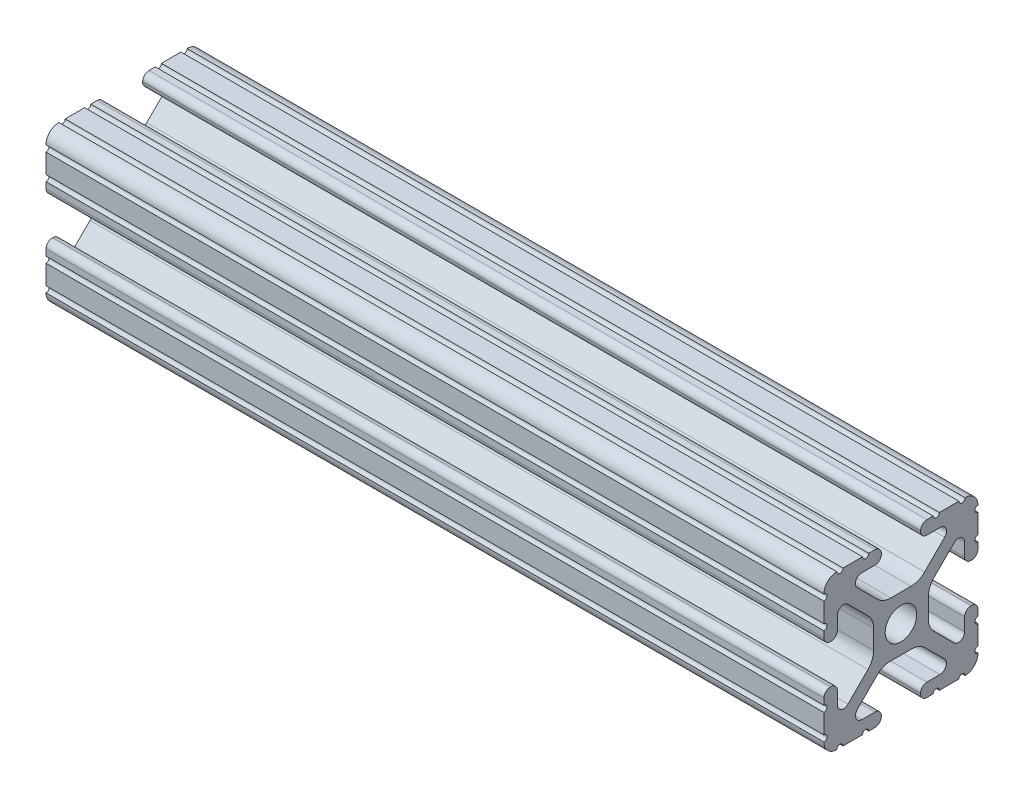
from build123d import *

# Parameters (mm, degrees)
SKETCH11_R                = 2.6035
F_10_1010_PROFILE_1_DEPTH = 128.27


with BuildPart() as part:
    # Sketch11 → 10 1010 PROFILE(1) (new body)
    with BuildSketch(Plane.ZY):
        with BuildLine():
            Line((-1.709253557, -4.4958), (1.709253557, -4.4958))
            ThreePointArc((1.709253557, -4.4958), (2.922935876, -4.736928798), (3.95226937, -5.423689619))
            Line((3.95226937, -5.423689619), (7.179652728, -8.645192207))
            ThreePointArc((7.179652728, -8.645192207), (7.414733441, -9.822812921), (6.41641086, -10.4902))
            Line((6.41641086, -10.4902), (4.28752, -10.4902))
            ThreePointArc((4.28752, -10.4902), (3.545750844, -10.797450844), (3.2385, -11.53922))
            Line((3.2385, -11.53922), (3.2385, -11.65098))
            ThreePointArc((3.2385, -11.65098), (3.545750844, -12.392749156), (4.28752, -12.7))
            Line((4.28752, -12.7), (5.3171344, -12.7))
            ThreePointArc((5.3171344, -12.7), (5.8251344, -12.192), (6.3331344, -12.7))
            Line((6.3331344, -12.7), (9.5504, -12.7))
            ThreePointArc((9.5504, -12.7), (10.058323491, -12.192000006), (10.566399977, -12.699846982))
            ThreePointArc((10.566399977, -12.699846982), (12.082522516, -12.082522516), (12.699846982, -10.566399977))
            ThreePointArc((12.699846982, -10.566399977), (12.192000006, -10.058323491), (12.7, -9.5504))
            Line((12.7, -9.5504), (12.7, -6.3330836))
            ThreePointArc((12.7, -6.3330836), (12.192, -5.8250836), (12.7, -5.3170836))
            Line((12.7, -5.3170836), (12.7, -4.287470133))
            ThreePointArc((12.7, -4.287470133), (12.392749156, -3.545700977), (11.65098, -3.238450133))
            Line((11.65098, -3.238450133), (11.53922, -3.238450133))
            ThreePointArc((11.53922, -3.238450133), (10.797450844, -3.545700977), (10.4902, -4.287470133))
            Line((10.4902, -4.287470133), (10.4902, -6.402089023))
            ThreePointArc((10.4902, -6.402089023), (9.856394933, -7.351113629), (8.736962546, -7.129240479))
            Line((8.736962546, -7.129240479), (5.440484187, -3.838768792))
            ThreePointArc((5.440484187, -3.838768792), (4.75073678, -2.808015636), (4.5085, -1.591658411))
            Line((4.5085, -1.591658411), (4.5085, 1.591658411))
            ThreePointArc((4.5085, 1.591658411), (4.75073678, 2.808015636), (5.440484187, 3.838768792))
            Line((5.440484187, 3.838768792), (8.736962546, 7.129240479))
            ThreePointArc((8.736962546, 7.129240479), (9.856394933, 7.351113629), (10.4902, 6.402089023))
            Line((10.4902, 6.402089023), (10.4902, 4.287470133))
            ThreePointArc((10.4902, 4.287470133), (10.797450844, 3.545700977), (11.53922, 3.238450133))
            Line((11.53922, 3.238450133), (11.65098, 3.238450133))
            ThreePointArc((11.65098, 3.238450133), (12.392749156, 3.545700977), (12.7, 4.287470133))
            Line((12.7, 4.287470133), (12.7, 5.3171344))
            ThreePointArc((12.7, 5.3171344), (12.192, 5.8251344), (12.7, 6.3331344))
            Line((12.7, 6.3331344), (12.7, 9.5504))
            ThreePointArc((12.7, 9.5504), (12.192000006, 10.058323491), (12.699846982, 10.566399977))
            ThreePointArc((12.699846982, 10.566399977), (12.082522516, 12.082522516), (10.566399977, 12.699846982))
            ThreePointArc((10.566399977, 12.699846982), (10.058323491, 12.192000006), (9.5504, 12.7))
            Line((9.5504, 12.7), (6.3330836, 12.7))
            ThreePointArc((6.3330836, 12.7), (5.8250836, 12.192), (5.3170836, 12.7))
            Line((5.3170836, 12.7), (4.2874692, 12.7))
            ThreePointArc((4.2874692, 12.7), (3.545700044, 12.392749156), (3.2384492, 11.65098))
            Line((3.2384492, 11.65098), (3.2384492, 11.53922))
            ThreePointArc((3.2384492, 11.53922), (3.545700044, 10.797450844), (4.2874692, 10.4902))
            Line((4.2874692, 10.4902), (6.476774195, 10.4902))
            ThreePointArc((6.476774195, 10.4902), (7.43216212, 9.851515102), (7.207191475, 8.724540082))
            Line((7.207191475, 8.724540082), (3.900315394, 5.423689619))
            ThreePointArc((3.900315394, 5.423689619), (2.8709819, 4.736928798), (1.657299581, 4.4958))
            Line((1.657299581, 4.4958), (-1.657299581, 4.4958))
            ThreePointArc((-1.657299581, 4.4958), (-2.8709819, 4.736928798), (-3.900315394, 5.423689619))
            Line((-3.900315394, 5.423689619), (-7.207191475, 8.724540082))
            ThreePointArc((-7.207191475, 8.724540082), (-7.43216212, 9.851515102), (-6.476774195, 10.4902))
            Line((-6.476774195, 10.4902), (-4.2874692, 10.4902))
            ThreePointArc((-4.2874692, 10.4902), (-3.545700044, 10.797450844), (-3.2384492, 11.53922))
            Line((-3.2384492, 11.53922), (-3.2384492, 11.65098))
            ThreePointArc((-3.2384492, 11.65098), (-3.545700044, 12.392749156), (-4.2874692, 12.7))
            Line((-4.2874692, 12.7), (-5.3170836, 12.7))
            ThreePointArc((-5.3170836, 12.7), (-5.8250836, 12.192), (-6.3330836, 12.7))
            Line((-6.3330836, 12.7), (-9.5504, 12.7))
            ThreePointArc((-9.5504, 12.7), (-10.058323491, 12.192000006), (-10.566399977, 12.699846982))
            ThreePointArc((-10.566399977, 12.699846982), (-12.082522516, 12.082522516), (-12.699846982, 10.566399977))
            ThreePointArc((-12.699846982, 10.566399977), (-12.192000006, 10.058323491), (-12.7, 9.5504))
            Line((-12.7, 9.5504), (-12.7, 6.3331344))
            ThreePointArc((-12.7, 6.3331344), (-12.192, 5.8251344), (-12.7, 5.3171344))
            Line((-12.7, 5.3171344), (-12.7, 4.287470133))
            ThreePointArc((-12.7, 4.287470133), (-12.392749156, 3.545700977), (-11.65098, 3.238450133))
            Line((-11.65098, 3.238450133), (-11.53922, 3.238450133))
            ThreePointArc((-11.53922, 3.238450133), (-10.797450844, 3.545700977), (-10.4902, 4.287470133))
            Line((-10.4902, 4.287470133), (-10.4902, 6.402089023))
            ThreePointArc((-10.4902, 6.402089023), (-9.856394933, 7.351113629), (-8.736962546, 7.129240479))
            Line((-8.736962546, 7.129240479), (-5.440484187, 3.838768792))
            ThreePointArc((-5.440484187, 3.838768792), (-4.75073678, 2.808015636), (-4.5085, 1.591658411))
            Line((-4.5085, 1.591658411), (-4.5085, -1.591658411))
            ThreePointArc((-4.5085, -1.591658411), (-4.75073678, -2.808015636), (-5.440484187, -3.838768792))
            Line((-5.440484187, -3.838768792), (-8.736962546, -7.129240479))
            ThreePointArc((-8.736962546, -7.129240479), (-9.856394933, -7.351113629), (-10.4902, -6.402089023))
            Line((-10.4902, -6.402089023), (-10.4902, -4.287470133))
            ThreePointArc((-10.4902, -4.287470133), (-10.797450844, -3.545700977), (-11.53922, -3.238450133))
            Line((-11.53922, -3.238450133), (-11.65098, -3.238450133))
            ThreePointArc((-11.65098, -3.238450133), (-12.392749156, -3.545700977), (-12.7, -4.287470133))
            Line((-12.7, -4.287470133), (-12.7, -5.3170836))
            ThreePointArc((-12.7, -5.3170836), (-12.192, -5.8250836), (-12.7, -6.3330836))
            Line((-12.7, -6.3330836), (-12.7, -9.5504))
            ThreePointArc((-12.7, -9.5504), (-12.192000006, -10.058323491), (-12.699846982, -10.566399977))
            ThreePointArc((-12.699846982, -10.566399977), (-12.082522516, -12.082522516), (-10.566399977, -12.699846982))
            ThreePointArc((-10.566399977, -12.699846982), (-10.058323491, -12.192000006), (-9.5504, -12.7))
            Line((-9.5504, -12.7), (-6.3331344, -12.7))
            ThreePointArc((-6.3331344, -12.7), (-5.8251344, -12.192), (-5.3171344, -12.7))
            Line((-5.3171344, -12.7), (-4.28752, -12.7))
            ThreePointArc((-4.28752, -12.7), (-3.545750844, -12.392749156), (-3.2385, -11.65098))
            Line((-3.2385, -11.65098), (-3.2385, -11.53922))
            ThreePointArc((-3.2385, -11.53922), (-3.545750844, -10.797450844), (-4.28752, -10.4902))
            Line((-4.28752, -10.4902), (-6.41641086, -10.4902))
            ThreePointArc((-6.41641086, -10.4902), (-7.414733441, -9.822812921), (-7.179652728, -8.645192207))
            Line((-7.179652728, -8.645192207), (-3.95226937, -5.423689619))
            ThreePointArc((-3.95226937, -5.423689619), (-2.922935876, -4.736928798), (-1.709253557, -4.4958))
        make_face()
        Circle(SKETCH11_R, mode=Mode.SUBTRACT)
    extrude(amount=F_10_1010_PROFILE_1_DEPTH)


solid = part.part
